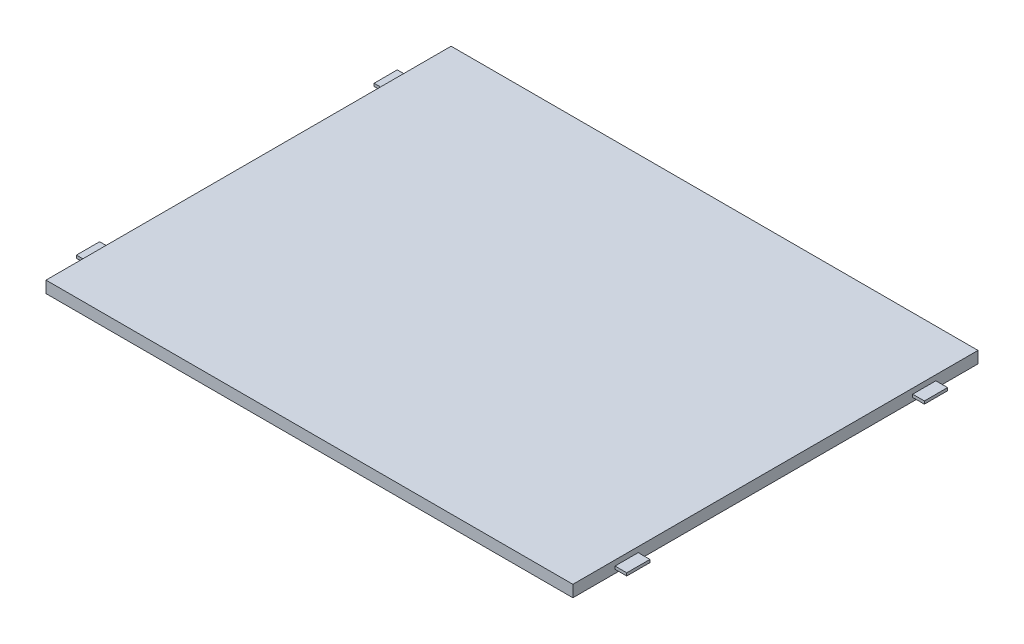
from build123d import *

# Parameters (mm, degrees)
SKETCH1_W           = 225
SKETCH1_H           = 173
BOSS_EXTRUDE1_DEPTH = 5
SKETCH2_W           = 9.9
SKETCH2_H           = 1.2
BOSS_EXTRUDE2_DEPTH = 5
SKETCH3_W           = 9.9
SKETCH3_H           = 1.2
BOSS_EXTRUDE3_DEPTH = 5


with BuildPart() as part:
    # Sketch1 → Boss-Extrude1 (new body)
    with BuildSketch(Plane(origin=(0, 0, 0), x_dir=(1, 0, 0), z_dir=(0, 1, 0))):
        with Locations((112.5, 86.5)):
            Rectangle(SKETCH1_W, SKETCH1_H)
    extrude(amount=BOSS_EXTRUDE1_DEPTH)

    # Sketch2 → Boss-Extrude2 (add)
    with BuildSketch(Plane.ZY):
        with Locations((-150.05, 2.15)):
            Rectangle(SKETCH2_W, SKETCH2_H)
        with Locations((-22.95, 2.15)):
            Rectangle(SKETCH2_W, SKETCH2_H)
    extrude(amount=BOSS_EXTRUDE2_DEPTH)

    # Sketch3 → Boss-Extrude3 (add)
    with BuildSketch(Plane(origin=(225, 0, 0), x_dir=(0, 0, -1), z_dir=(1, 0, 0))):
        with Locations((22.95, 2.15)):
            Rectangle(SKETCH3_W, SKETCH3_H)
        with Locations((150.05, 2.15)):
            Rectangle(SKETCH3_W, SKETCH3_H)
    extrude(amount=BOSS_EXTRUDE3_DEPTH)


solid = part.part
